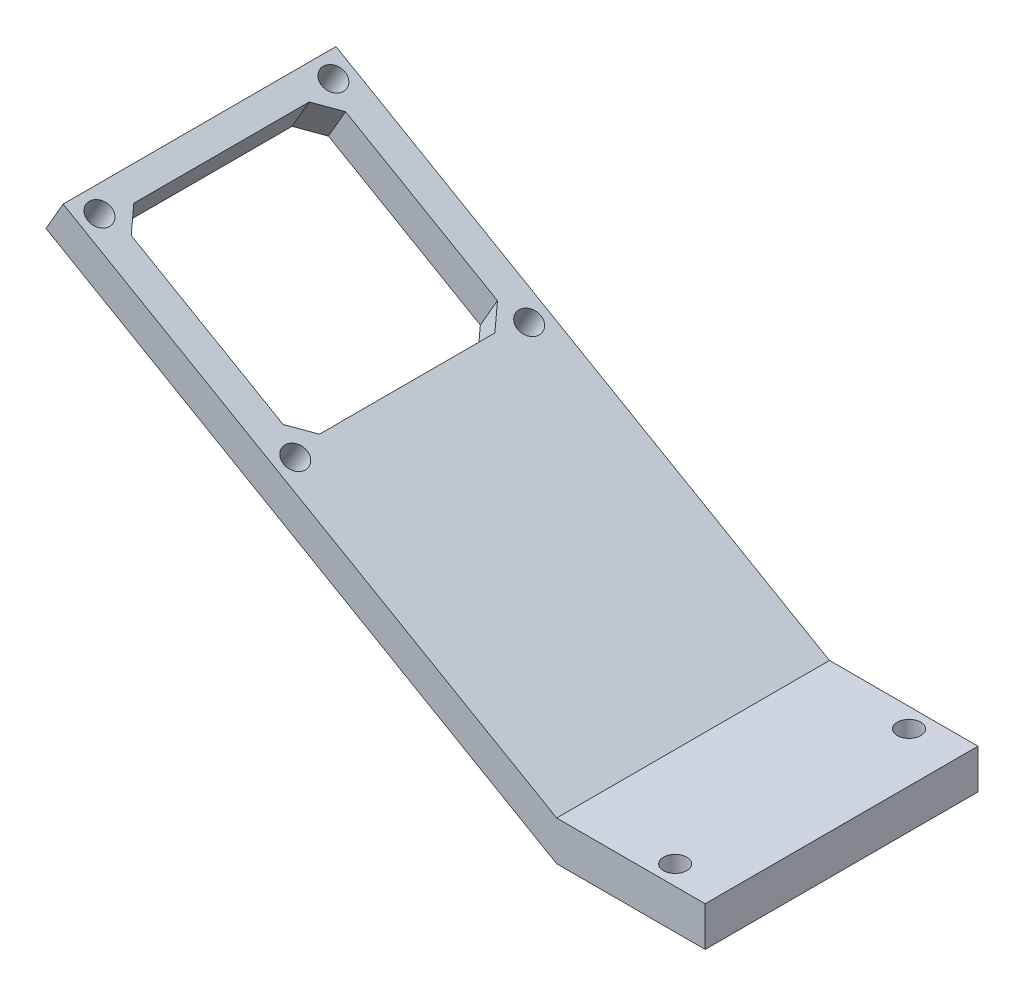
from build123d import *

# Parameters (mm, degrees)
SKETCH2_W                       = 19.05
SKETCH2_H                       = 5.08
BOSS_EXTRUDE1_DEPTH             = 35
SKETCH3_W                       = 25
SKETCH3_H                       = 25
CUT_EXTRUDE1_DEPTH              = 38.152489822
F_3_0MM_DOWEL_HOLE1_D           = 3
F_3_0MM_DOWEL_HOLE1_ON_FACE_2_D = 3
F_3_0MM_DOWEL_HOLE1_ON_FACE_3_D = 3
F_3_0MM_DOWEL_HOLE2_D           = 3


with BuildPart() as part:
    # Sketch2 → Boss-Extrude1 (new body)
    with BuildSketch(Plane.XY):
        Polygon((-65.506161542, 32.74), (-63.306457017, 36.55), (-32.995567884, 19.05), (-35.19527241, 15.24), align=None)
        Polygon((-32.995567884, 19.05), (0, 0), (0, -5.08), (-35.19527241, 15.24), align=None)
        with Locations((9.525, -2.54)):
            Rectangle(SKETCH2_W, SKETCH2_H)
    extrude(amount=BOSS_EXTRUDE1_DEPTH)

    # Sketch3 → Cut-Extrude1 (cut, through all)
    with BuildSketch(Plane(origin=(0, 0, 0), x_dir=(0.866025404, -0.5, 0), z_dir=(0.5, 0.866025404, 0))):
        with Locations((-56.1, -17.5)):
            Rectangle(SKETCH3_W, SKETCH3_H)
        Polygon((-67.35, -3.75), (-68.6, -5), (-43.6, -5), (-44.85, -3.75), align=None)
        Polygon((-68.6, -30), (-68.6, -5), (-69.85, -6.25), (-69.85, -28.75), align=None)
        Polygon((-42.35, -6.25), (-43.6, -5), (-43.6, -30), (-42.35, -28.75), align=None)
        Polygon((-43.6, -30), (-68.6, -30), (-67.35, -31.25), (-44.85, -31.25), align=None)
    extrude(amount=-CUT_EXTRUDE1_DEPTH, mode=Mode.SUBTRACT)

    # Ø3.0mm Dowel Hole1 (through all)
    with Locations(Plane(origin=(-61.141393507, 35.3, 2.5), x_dir=(0.866025404, -0.5, 0), z_dir=(0.5, 0.866025404, 0))):
        with Locations((0, 0)):
            Hole(F_3_0MM_DOWEL_HOLE1_D / 2)

    # Ø3.0mm Dowel Hole1 on face 2 (through all)
    with Locations(Plane(origin=(-36.026656797, 20.8, 2.5), x_dir=(0.866025303, -0.500000175, 0), z_dir=(0.500000175, 0.866025303, 0))):
        with Locations((0, 0), (0, -30)):
            Hole(F_3_0MM_DOWEL_HOLE1_ON_FACE_2_D / 2)

    # Ø3.0mm Dowel Hole1 on face 3 (through all)
    with Locations(Plane(origin=(-61.141393507, 35.3, 32.5), x_dir=(0.866025303, -0.500000175, 0), z_dir=(0.500000175, 0.866025303, 0))):
        with Locations((0, 0)):
            Hole(F_3_0MM_DOWEL_HOLE1_ON_FACE_3_D / 2)

    # Ø3.0mm Dowel Hole2 (through all)
    with Locations(Plane(origin=(12.7, 0, 2.5), x_dir=(1, 0, 0), z_dir=(0, 1, 0))):
        with Locations((0, 0), (0, -30)):
            Hole(F_3_0MM_DOWEL_HOLE2_D / 2)


solid = part.part
